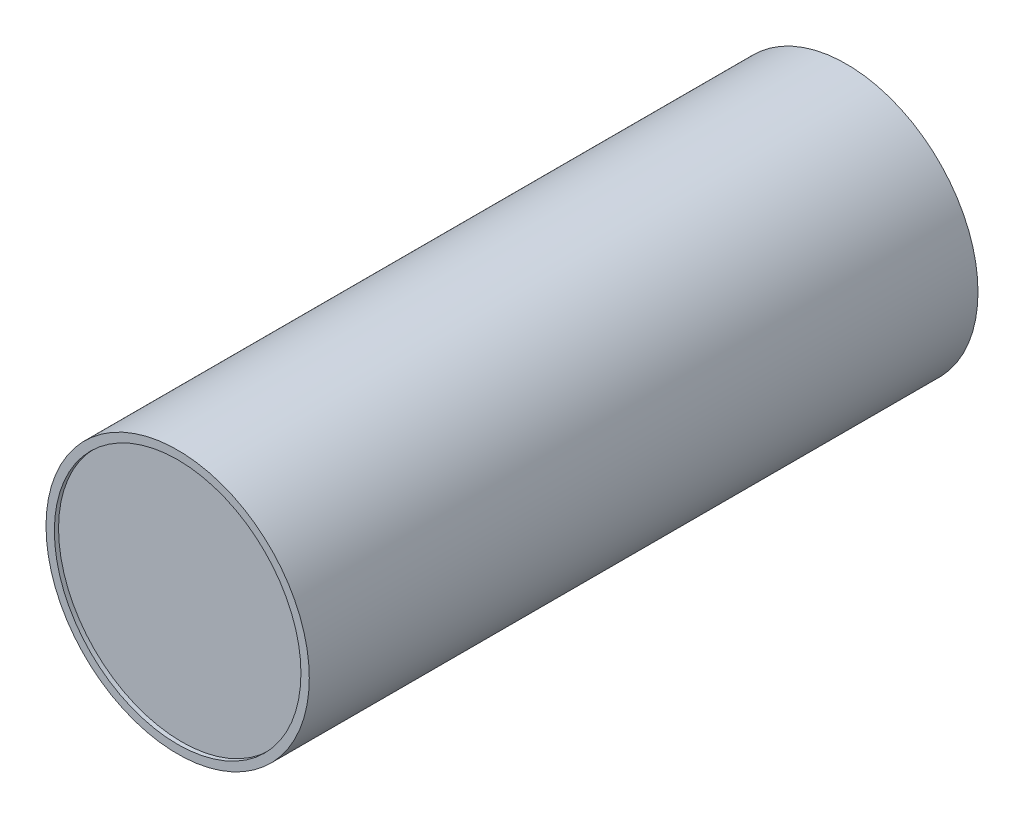
from build123d import *

# Parameters (mm, degrees)
ESQUISSE1_R        = 31.5
ESQUISSE1_R_2      = 29.5
BOSS_EXTRU_1_DEPTH = 160
ESQUISSE2_R        = 30
BOSS_EXTRU_2_DEPTH = 5
ESQUISSE3_R        = 30
BOSS_EXTRU_3_DEPTH = 5


with BuildPart() as part:
    # Esquisse1 → Boss.-Extru.1 (new body)
    with BuildSketch(Plane.XY):
        Circle(ESQUISSE1_R)
        Circle(ESQUISSE1_R_2, mode=Mode.SUBTRACT)
    extrude(amount=BOSS_EXTRU_1_DEPTH)

    # Esquisse2 → Boss.-Extru.2 (add)
    with BuildSketch(Plane(origin=(0, 0, 1), x_dir=(-1, 0, 0), z_dir=(0, 0, -1))):
        Circle(ESQUISSE2_R)
    extrude(amount=-BOSS_EXTRU_2_DEPTH)

    # Esquisse3 → Boss.-Extru.3 (add)
    with BuildSketch(Plane.XY.offset(159)):
        Circle(ESQUISSE3_R)
    extrude(amount=-BOSS_EXTRU_3_DEPTH)


solid = part.part
